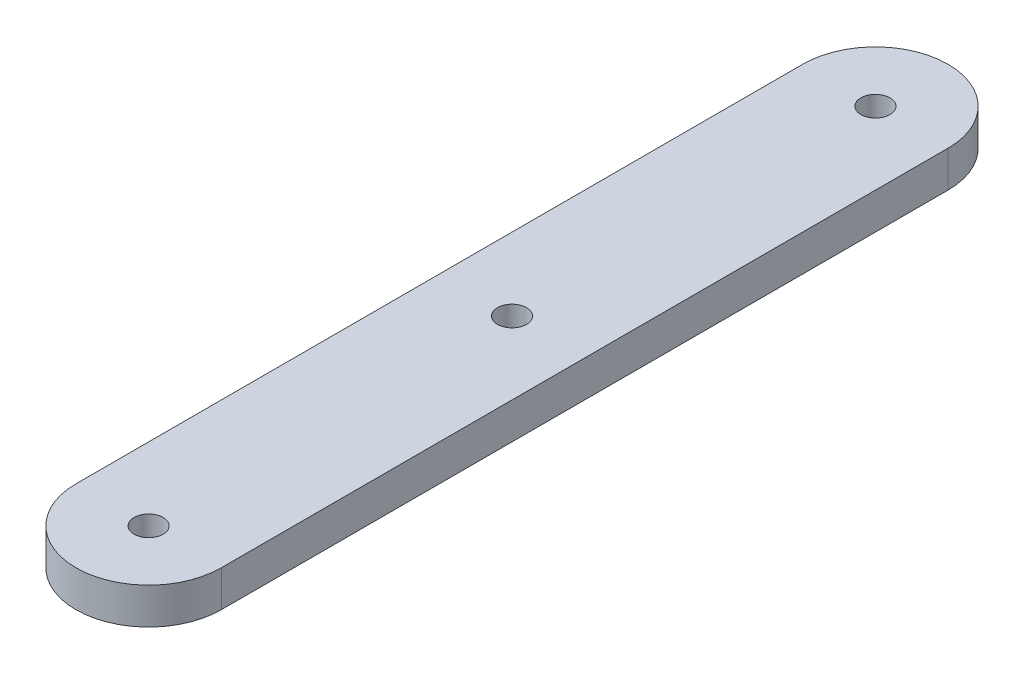
from build123d import *

# Parameters (mm, degrees)
SKETCH2_R           = 1.27
BOSS_EXTRUDE1_DEPTH = 3.175


with BuildPart() as part:
    # Sketch2 → Boss-Extrude1 (new body)
    with BuildSketch(Plane(origin=(0, 0, 0), x_dir=(1, 0, 0), z_dir=(0, 1, 0))):
        with BuildLine():
            Line((-6.35, -31.75), (-6.35, 31.75))
            ThreePointArc((-6.35, 31.75), (0, 38.1), (6.35, 31.75))
            Line((6.35, 31.75), (6.35, -31.75))
            ThreePointArc((6.35, -31.75), (0, -38.1), (-6.35, -31.75))
        make_face()
        with Locations((0, 31.75)):
            Circle(SKETCH2_R, mode=Mode.SUBTRACT)
        with Locations((0, -31.75)):
            Circle(SKETCH2_R, mode=Mode.SUBTRACT)
        Circle(SKETCH2_R, mode=Mode.SUBTRACT)
    extrude(amount=BOSS_EXTRUDE1_DEPTH)


solid = part.part
